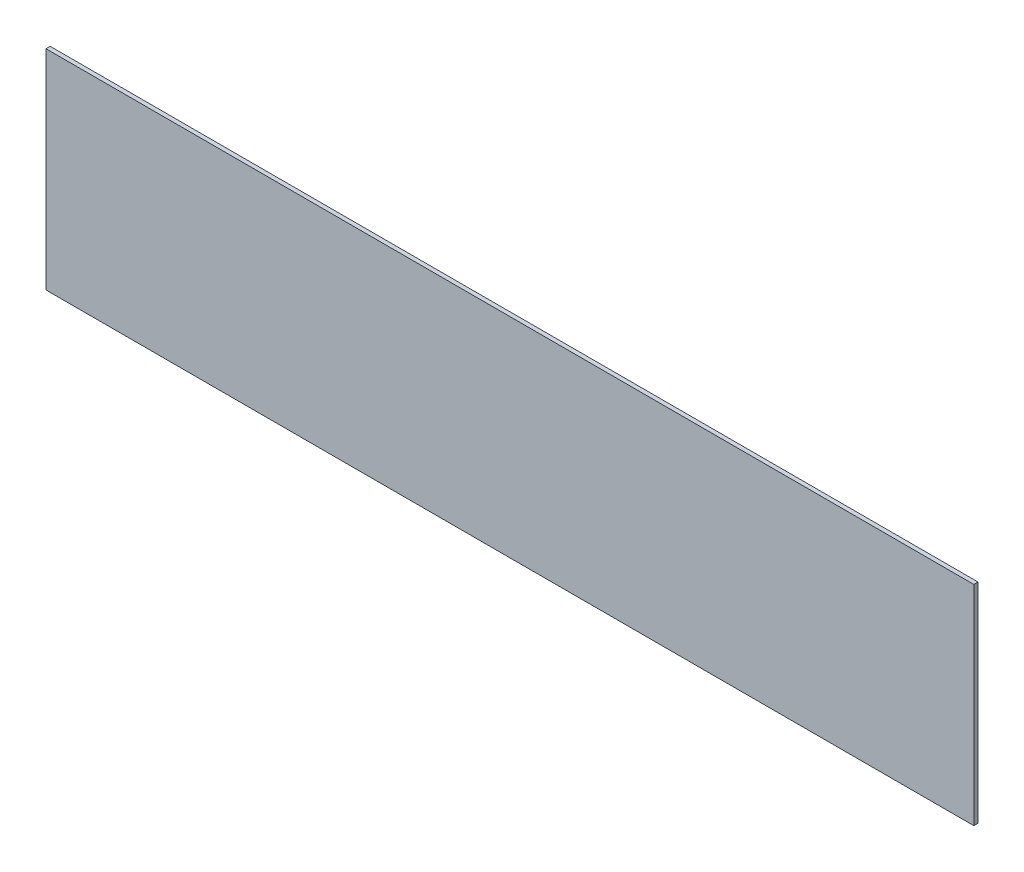
from build123d import *

# Parameters (mm, degrees)
SKETCH1_W           = 222
SKETCH1_H           = 50
BOSS_EXTRUDE1_DEPTH = 1


with BuildPart() as part:
    # Sketch1 → Boss-Extrude1 (new body)
    with BuildSketch(Plane.XY):
        with Locations((54.773176128, 18.637823085)):
            Rectangle(SKETCH1_W, SKETCH1_H)
    extrude(amount=BOSS_EXTRUDE1_DEPTH)


solid = part.part
